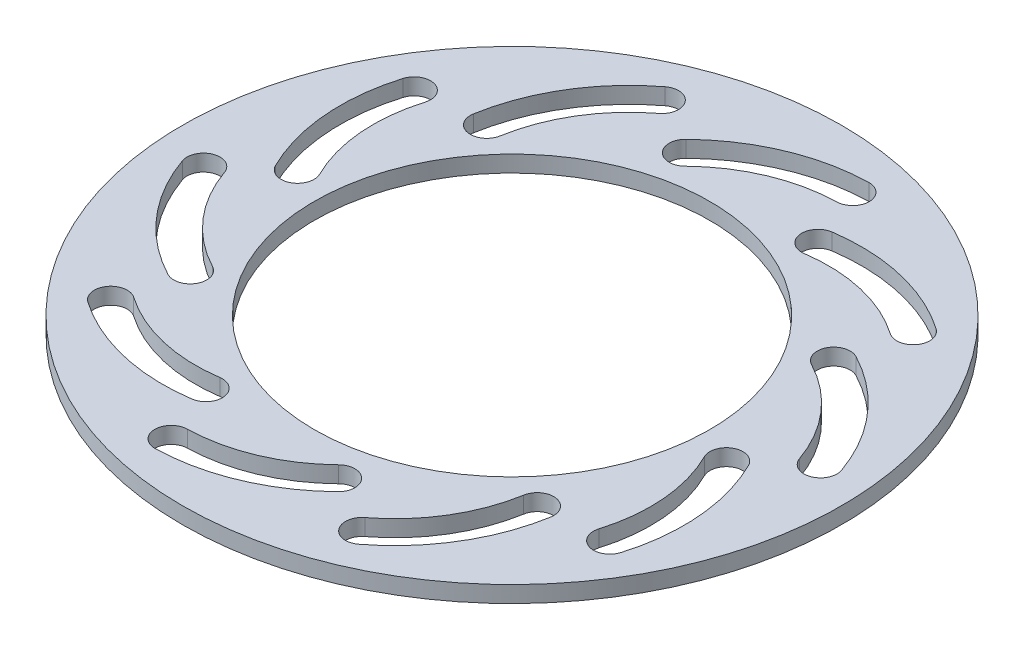
from build123d import *

# Parameters (mm, degrees)
SKETCH2_R           = 100
SKETCH2_R_2         = 60
BOSS_EXTRUDE1_DEPTH = 5


with BuildPart() as part:
    # Sketch2 → Boss-Extrude1 (new body)
    with BuildSketch(Plane(origin=(0, 0, 0), x_dir=(1, 0, 0), z_dir=(0, 1, 0))):
        Circle(SKETCH2_R)
        Circle(SKETCH2_R_2, mode=Mode.SUBTRACT)
        with BuildLine():
            ThreePointArc((19.163333379, 89.106772861), (-1.936913189, 84.609595134), (-19.916532707, 72.685741114))
            ThreePointArc((-19.916532707, 72.685741114), (-20.001448799, 65.615183198), (-12.930890882, 65.530267106))
            ThreePointArc((-12.930890882, 65.530267106), (1.936913189, 75.390404866), (19.385243032, 79.109235359))
            ThreePointArc((19.385243032, 79.109235359), (24.273056956, 84.218958937), (19.163333379, 89.106772861))
        make_face(mode=Mode.SUBTRACT)
        with BuildLine():
            ThreePointArc((67.879109339, 60.824968814), (48.165276536, 69.589089358), (26.61079325, 70.510644013))
            ThreePointArc((26.61079325, 70.510644013), (22.386125019, 64.840354924), (28.056414107, 60.615686694))
            ThreePointArc((28.056414107, 60.615686694), (45.880363831, 59.853629742), (62.182232917, 52.606355851))
            ThreePointArc((62.182232917, 52.606355851), (69.139977609, 53.867224121), (67.879109339, 60.824968814))
        make_face(mode=Mode.SUBTRACT)
        with BuildLine():
            ThreePointArc((90.667372658, 9.310094044), (79.869967701, 27.987916693), (62.973700653, 41.402877466))
            ThreePointArc((62.973700653, 41.402877466), (56.222959957, 39.298714913), (58.32712251, 32.547974217))
            ThreePointArc((58.32712251, 32.547974217), (72.299074906, 21.454802407), (81.227723324, 6.009636433))
            ThreePointArc((81.227723324, 6.009636433), (87.597776797, 2.940040571), (90.667372658, 9.310094044))
        make_face(mode=Mode.SUBTRACT)
        with BuildLine():
            ThreePointArc((78.823781293, -45.760920212), (81.067045885, -24.303688874), (75.282794804, -3.51938104))
            ThreePointArc((75.282794804, -3.51938104), (68.584535139, -1.253698481), (66.31885258, -7.951958147))
            ThreePointArc((66.31885258, -7.951958147), (71.101996722, -25.139030226), (69.24698425, -42.882559843))
            ThreePointArc((69.24698425, -42.882559843), (72.596202587, -49.110138549), (78.823781293, -45.760920212))
        make_face(mode=Mode.SUBTRACT)
        with BuildLine():
            ThreePointArc((36.872184595, -83.352818303), (51.299267908, -67.312111343), (58.836420108, -47.097355608))
            ThreePointArc((58.836420108, -47.097355608), (54.749149001, -41.327241667), (48.97903506, -45.414512775))
            ThreePointArc((48.97903506, -45.414512775), (42.746372458, -62.130607757), (30.816250811, -75.395075784))
            ThreePointArc((30.816250811, -75.395075784), (29.865346443, -82.401913935), (36.872184595, -83.352818303))
        make_face(mode=Mode.SUBTRACT)
        with BuildLine():
            ThreePointArc((-19.163333379, -89.106772861), (1.936913189, -84.609595134), (19.916532707, -72.685741114))
            ThreePointArc((19.916532707, -72.685741114), (20.001448799, -65.615183198), (12.930890882, -65.530267106))
            ThreePointArc((12.930890882, -65.530267106), (-1.936913189, -75.390404866), (-19.385243032, -79.109235359))
            ThreePointArc((-19.385243032, -79.109235359), (-24.273056956, -84.218958937), (-19.163333379, -89.106772861))
        make_face(mode=Mode.SUBTRACT)
        with BuildLine():
            ThreePointArc((-67.879109339, -60.824968814), (-48.165276536, -69.589089358), (-26.61079325, -70.510644013))
            ThreePointArc((-26.61079325, -70.510644013), (-22.386125019, -64.840354924), (-28.056414107, -60.615686694))
            ThreePointArc((-28.056414107, -60.615686694), (-45.880363831, -59.853629742), (-62.182232917, -52.606355851))
            ThreePointArc((-62.182232917, -52.606355851), (-69.139977609, -53.867224121), (-67.879109339, -60.824968814))
        make_face(mode=Mode.SUBTRACT)
        with BuildLine():
            ThreePointArc((-90.667372658, -9.310094044), (-79.869967701, -27.987916693), (-62.973700653, -41.402877466))
            ThreePointArc((-62.973700653, -41.402877466), (-56.222959957, -39.298714913), (-58.32712251, -32.547974217))
            ThreePointArc((-58.32712251, -32.547974217), (-72.299074906, -21.454802407), (-81.227723324, -6.009636433))
            ThreePointArc((-81.227723324, -6.009636433), (-87.597776797, -2.940040571), (-90.667372658, -9.310094044))
        make_face(mode=Mode.SUBTRACT)
        with BuildLine():
            ThreePointArc((-78.823781293, 45.760920212), (-81.067045885, 24.303688874), (-75.282794804, 3.51938104))
            ThreePointArc((-75.282794804, 3.51938104), (-68.584535139, 1.253698481), (-66.31885258, 7.951958147))
            ThreePointArc((-66.31885258, 7.951958147), (-71.101996722, 25.139030226), (-69.24698425, 42.882559843))
            ThreePointArc((-69.24698425, 42.882559843), (-72.596202587, 49.110138549), (-78.823781293, 45.760920212))
        make_face(mode=Mode.SUBTRACT)
        with BuildLine():
            ThreePointArc((-36.872184595, 83.352818303), (-51.299267908, 67.312111343), (-58.836420108, 47.097355608))
            ThreePointArc((-58.836420108, 47.097355608), (-54.749149001, 41.327241667), (-48.97903506, 45.414512775))
            ThreePointArc((-48.97903506, 45.414512775), (-42.746372458, 62.130607757), (-30.816250811, 75.395075784))
            ThreePointArc((-30.816250811, 75.395075784), (-29.865346443, 82.401913935), (-36.872184595, 83.352818303))
        make_face(mode=Mode.SUBTRACT)
    extrude(amount=BOSS_EXTRUDE1_DEPTH)


solid = part.part
